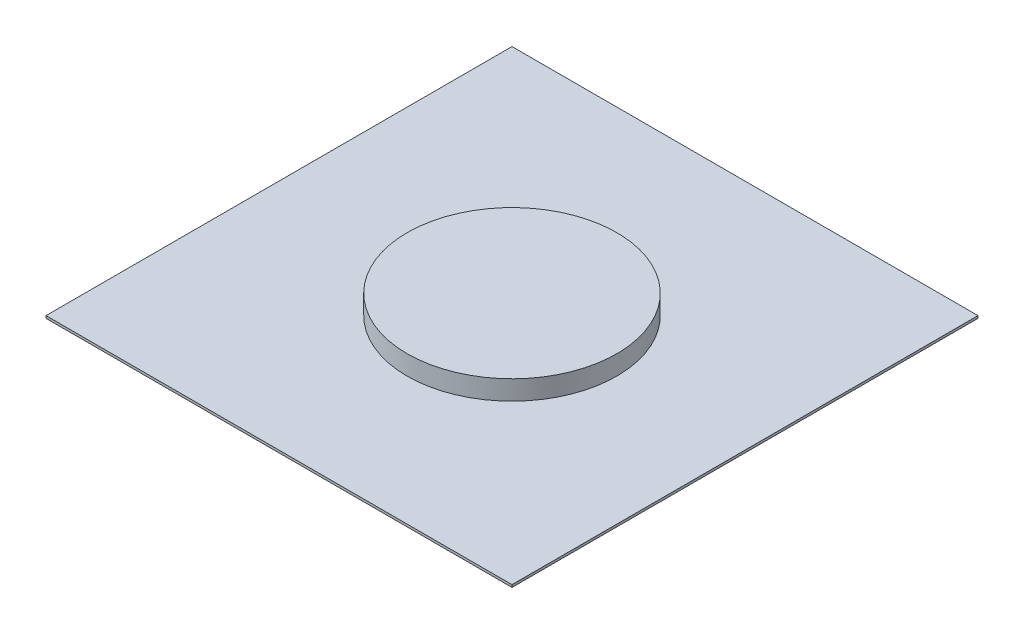
from build123d import *

# Parameters (mm, degrees)
SKETCH1_W      = 609.6
SKETCH1_H      = 609.6
EXTRUDE1_DEPTH = 3.175
SKETCH3_R      = 137.175010905
EXTRUDE2_DEPTH = 25.4


with BuildPart() as part:
    # Sketch1 → Extrude1 (new body)
    with BuildSketch(Plane(origin=(0, 0, 0), x_dir=(1, 0, 0), z_dir=(0, 1, 0))):
        Rectangle(SKETCH1_W, SKETCH1_H)
    extrude(amount=-EXTRUDE1_DEPTH)


with BuildPart() as body_2:
    # sketch3 → Extrude2 (new body)
    with BuildSketch(Plane(origin=(0, 0, 0), x_dir=(-1, 0, 0), z_dir=(0, 1, 0))):
        Circle(SKETCH3_R)
    extrude(amount=EXTRUDE2_DEPTH)


solid = Compound([part.part, body_2.part])
